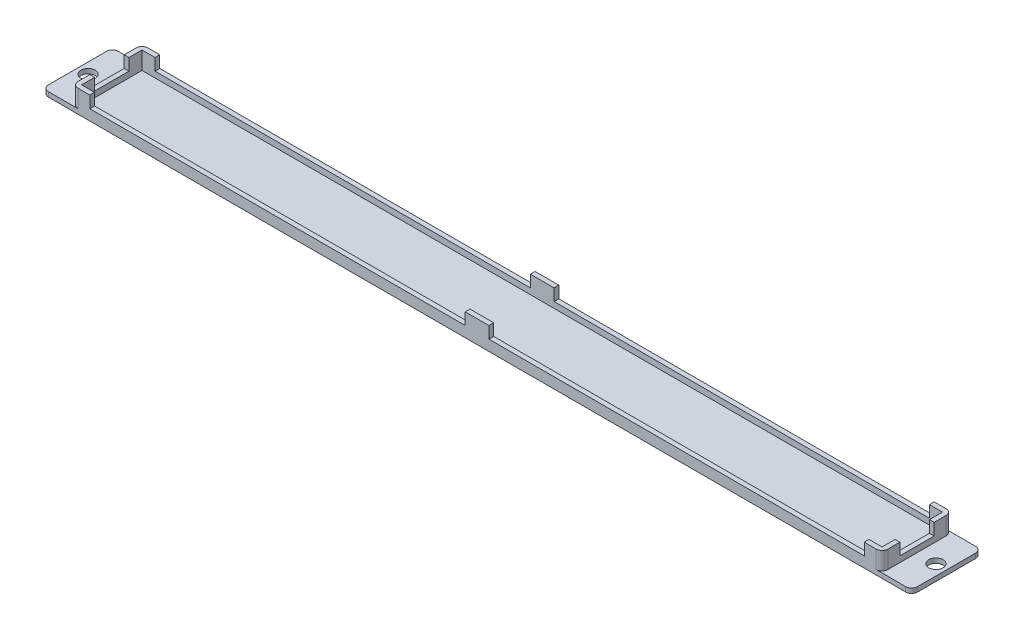
from build123d import *

# Parameters (mm, degrees)
ESQUISSE1_W             = 136.8
ESQUISSE1_H             = 11.8
BOSS_EXTRU_1_DEPTH      = 0.8
ESQUISSE2_W             = 136.8
ESQUISSE2_H             = 11.8
ESQUISSE2_W_2           = 135.2
ESQUISSE2_H_2           = 10.2
BOSS_EXTRU_2_DEPTH      = 1
ESQUISSE3_W             = 4
ESQUISSE3_H             = 0.8
BOSS_EXTRU_3_DEPTH      = 2
ESQUISSE4_W             = 11.8
ESQUISSE4_H             = 0.8
BOSS_EXTRU_4_DEPTH      = 5
ESQUISSE5_W             = 11.8
ESQUISSE5_H             = 0.8
BOSS_EXTRU_5_DEPTH      = 5
ESQUISSE6_R             = 1.2
ENL_V_MAT_EXTRU_1_DEPTH = 4
CONG_1_R                = 1


with BuildPart() as part:
    # Esquisse1 → Boss.-Extru.1 (new body)
    with BuildSketch(Plane(origin=(0, 0, 0), x_dir=(1, 0, 0), z_dir=(0, 1, 0))):
        with Locations((68.4, 5.9)):
            Rectangle(ESQUISSE1_W, ESQUISSE1_H)
    extrude(amount=BOSS_EXTRU_1_DEPTH)

    # Esquisse2 → Boss.-Extru.2 (add)
    with BuildSketch(Plane(origin=(0, 0.8, 0), x_dir=(1, 0, 0), z_dir=(0, 1, 0))):
        with Locations((68.4, 5.9)):
            Rectangle(ESQUISSE2_W, ESQUISSE2_H)
        with Locations((68.4, 5.9)):
            Rectangle(ESQUISSE2_W_2, ESQUISSE2_H_2, mode=Mode.SUBTRACT)
    extrude(amount=BOSS_EXTRU_2_DEPTH)

    # Esquisse3 → Boss.-Extru.3 (add)
    with BuildSketch(Plane(origin=(0, 1.8, 0), x_dir=(1, 0, 0), z_dir=(0, 1, 0))):
        Polygon((0.8, 3), (0, 3), (0, 0), (3, 0), (3, 0.8), (0.8, 0.8), align=None)
        Polygon((3, 11.8), (0, 11.8), (0, 8.8), (0.8, 8.8), (0.8, 11), (3, 11), align=None)
        Polygon((133.8, 11), (136, 11), (136, 8.8), (136.8, 8.8), (136.8, 11.8), (133.8, 11.8), align=None)
        with Locations((68.4, 11.4)):
            Rectangle(ESQUISSE3_W, ESQUISSE3_H)
        with Locations((68.4, 0.4)):
            Rectangle(ESQUISSE3_W, ESQUISSE3_H)
        Polygon((133.8, 0), (136.8, 0), (136.8, 3), (136, 3), (136, 0.8), (133.8, 0.8), align=None)
    extrude(amount=BOSS_EXTRU_3_DEPTH)

    # Esquisse4 → Boss.-Extru.4 (add)
    with BuildSketch(Plane(origin=(136.8, 0, 0), x_dir=(0, 0, -1), z_dir=(1, 0, 0))):
        with Locations((5.9, 0.4)):
            Rectangle(ESQUISSE4_W, ESQUISSE4_H)
    extrude(amount=BOSS_EXTRU_4_DEPTH)

    # Esquisse5 → Boss.-Extru.5 (add)
    with BuildSketch(Plane.ZY):
        with Locations((-5.9, 0.4)):
            Rectangle(ESQUISSE5_W, ESQUISSE5_H)
    extrude(amount=BOSS_EXTRU_5_DEPTH)

    # Esquisse6 → Enlèv. mat.-Extru.1 (cut)
    with BuildSketch(Plane.XZ):
        with Locations((140, -5.9)):
            Circle(ESQUISSE6_R)
        with Locations((-3.2, -5.9)):
            Circle(ESQUISSE6_R)
    extrude(amount=-ENL_V_MAT_EXTRU_1_DEPTH, mode=Mode.SUBTRACT)

    # Congé1
    cong_1_edges = [part.edges().sort_by_distance(p)[0] for p in [
        (141.8, 0.4, -11.8),
        (141.8, 0.4, 0),
        (-5, 0.4, -11.8),
        (-5, 0.4, 0),
        (0, 2.3, -11.8),
        (136.8, 2.3, -11.8),
        (136.8, 2.3, 0),
        (0, 2.3, 0),
    ]]
    fillet(cong_1_edges, radius=CONG_1_R)


solid = part.part
